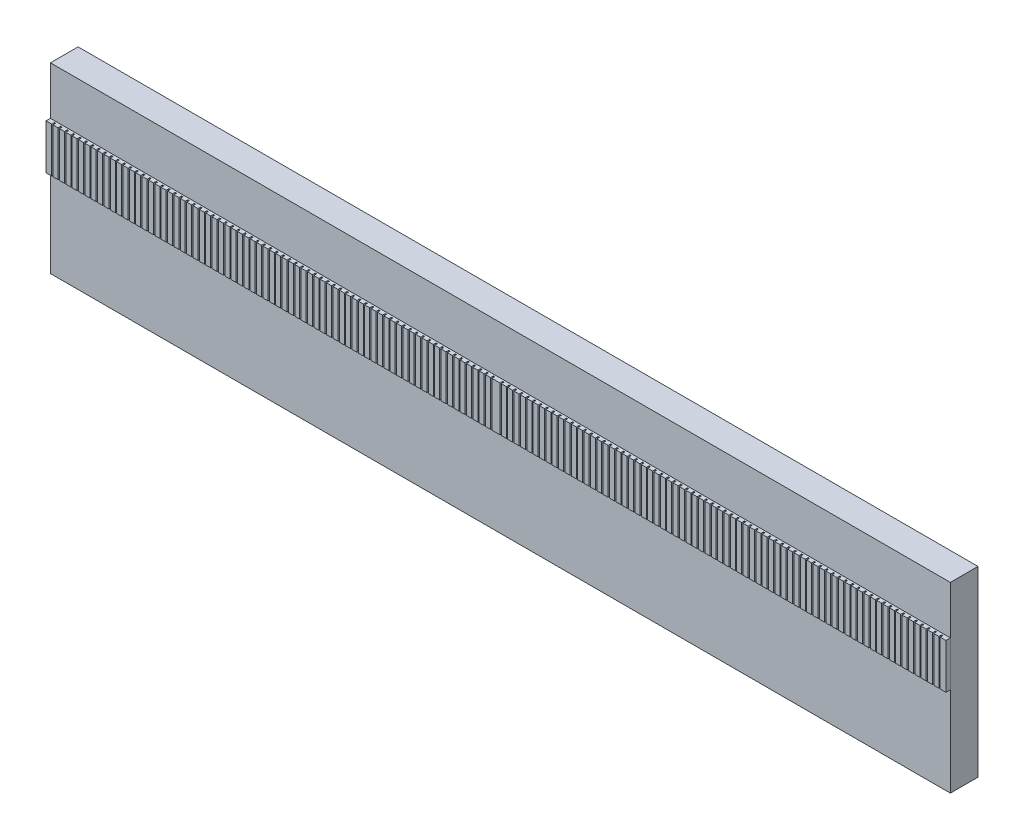
from build123d import *

# Parameters (mm, degrees)
SKETCH1_W           = 32.54
SKETCH1_H           = 6.6
BOSS_EXTRUDE1_DEPTH = 1
SKETCH2_W           = 32.54
SKETCH2_H           = 1.625
BOSS_EXTRUDE2_DEPTH = 0.16
SKETCH3_R           = 0.225
BOSS_EXTRUDE3_DEPTH = 0.25
FILLET1_R           = 0.22
SKETCH5_W           = 0.05
SKETCH5_H           = 1.625
CUT_EXTRUDE1_DEPTH  = 0.1


with BuildPart() as part:
    # Sketch1 → Boss-Extrude1 (new body)
    with BuildSketch(Plane.XY):
        Rectangle(SKETCH1_W, SKETCH1_H)
    extrude(amount=BOSS_EXTRUDE1_DEPTH)

    # Sketch3 → Boss-Extrude3 (add)
    with BuildSketch(Plane(origin=(0, 0, 0), x_dir=(-1, 0, 0), z_dir=(0, 0, -1))):
        with Locations((-0.49, 0.75)):
            Circle(SKETCH3_R)
        with Locations((-1.47, 0.75)):
            Circle(SKETCH3_R)
        with Locations((-2.45, 0.75)):
            Circle(SKETCH3_R)
        with Locations((-3.43, 0.75)):
            Circle(SKETCH3_R)
        with Locations((-4.41, 0.75)):
            Circle(SKETCH3_R)
        with Locations((-5.39, 0.75)):
            Circle(SKETCH3_R)
        with Locations((-6.37, 0.75)):
            Circle(SKETCH3_R)
        with Locations((-7.35, 0.75)):
            Circle(SKETCH3_R)
        with Locations((-8.33, 0.75)):
            Circle(SKETCH3_R)
        with Locations((-9.31, 0.75)):
            Circle(SKETCH3_R)
        with Locations((-10.29, 0.75)):
            Circle(SKETCH3_R)
        with Locations((-11.27, 0.75)):
            Circle(SKETCH3_R)
        with Locations((-12.25, 0.75)):
            Circle(SKETCH3_R)
        with Locations((-13.23, 0.75)):
            Circle(SKETCH3_R)
        with Locations((-14.21, 0.75)):
            Circle(SKETCH3_R)
        with Locations((-15.19, 0.75)):
            Circle(SKETCH3_R)
        with Locations((0, 2.3)):
            Circle(SKETCH3_R)
        with Locations((-0.98, 2.3)):
            Circle(SKETCH3_R)
        with Locations((-1.96, 2.3)):
            Circle(SKETCH3_R)
        with Locations((-2.94, 2.3)):
            Circle(SKETCH3_R)
        with Locations((-3.92, 2.3)):
            Circle(SKETCH3_R)
        with Locations((-4.9, 2.3)):
            Circle(SKETCH3_R)
        with Locations((-5.88, 2.3)):
            Circle(SKETCH3_R)
        with Locations((-6.86, 2.3)):
            Circle(SKETCH3_R)
        with Locations((-7.84, 2.3)):
            Circle(SKETCH3_R)
        with Locations((-8.82, 2.3)):
            Circle(SKETCH3_R)
        with Locations((-9.8, 2.3)):
            Circle(SKETCH3_R)
        with Locations((-10.78, 2.3)):
            Circle(SKETCH3_R)
        with Locations((-11.76, 2.3)):
            Circle(SKETCH3_R)
        with Locations((-12.74, 2.3)):
            Circle(SKETCH3_R)
        with Locations((-13.72, 2.3)):
            Circle(SKETCH3_R)
        with Locations((-14.7, 2.3)):
            Circle(SKETCH3_R)
        with Locations((-15.68, 2.3)):
            Circle(SKETCH3_R)
        with Locations((-0.49, 2.9)):
            Circle(SKETCH3_R)
        with Locations((-1.47, 2.9)):
            Circle(SKETCH3_R)
        with Locations((-2.45, 2.9)):
            Circle(SKETCH3_R)
        with Locations((-3.43, 2.9)):
            Circle(SKETCH3_R)
        with Locations((-4.41, 2.9)):
            Circle(SKETCH3_R)
        with Locations((-5.39, 2.9)):
            Circle(SKETCH3_R)
        with Locations((-6.37, 2.9)):
            Circle(SKETCH3_R)
        with Locations((-7.35, 2.9)):
            Circle(SKETCH3_R)
        with Locations((-8.33, 2.9)):
            Circle(SKETCH3_R)
        with Locations((-9.31, 2.9)):
            Circle(SKETCH3_R)
        with Locations((-10.29, 2.9)):
            Circle(SKETCH3_R)
        with Locations((-11.27, 2.9)):
            Circle(SKETCH3_R)
        with Locations((-12.25, 2.9)):
            Circle(SKETCH3_R)
        with Locations((-13.23, 2.9)):
            Circle(SKETCH3_R)
        with Locations((-14.21, 2.9)):
            Circle(SKETCH3_R)
        with Locations((-15.19, 2.9)):
            Circle(SKETCH3_R)
        with Locations((0.49, 0.75)):
            Circle(SKETCH3_R)
        with Locations((1.47, 0.75)):
            Circle(SKETCH3_R)
        with Locations((2.45, 0.75)):
            Circle(SKETCH3_R)
        with Locations((3.43, 0.75)):
            Circle(SKETCH3_R)
        with Locations((4.41, 0.75)):
            Circle(SKETCH3_R)
        with Locations((5.39, 0.75)):
            Circle(SKETCH3_R)
        with Locations((6.37, 0.75)):
            Circle(SKETCH3_R)
        with Locations((7.35, 0.75)):
            Circle(SKETCH3_R)
        with Locations((8.33, 0.75)):
            Circle(SKETCH3_R)
        with Locations((9.31, 0.75)):
            Circle(SKETCH3_R)
        with Locations((10.29, 0.75)):
            Circle(SKETCH3_R)
        with Locations((11.27, 0.75)):
            Circle(SKETCH3_R)
        with Locations((12.25, 0.75)):
            Circle(SKETCH3_R)
        with Locations((13.23, 0.75)):
            Circle(SKETCH3_R)
        with Locations((14.21, 0.75)):
            Circle(SKETCH3_R)
        with Locations((15.19, 0.75)):
            Circle(SKETCH3_R)
        with Locations((15.68, 2.3)):
            Circle(SKETCH3_R)
        with Locations((14.7, 2.3)):
            Circle(SKETCH3_R)
        with Locations((15.19, 2.9)):
            Circle(SKETCH3_R)
        with Locations((14.21, 2.9)):
            Circle(SKETCH3_R)
        with Locations((13.72, 2.3)):
            Circle(SKETCH3_R)
        with Locations((12.74, 2.3)):
            Circle(SKETCH3_R)
        with Locations((13.23, 2.9)):
            Circle(SKETCH3_R)
        with Locations((12.25, 2.9)):
            Circle(SKETCH3_R)
        with Locations((11.76, 2.3)):
            Circle(SKETCH3_R)
        with Locations((11.27, 2.9)):
            Circle(SKETCH3_R)
        with Locations((10.78, 2.3)):
            Circle(SKETCH3_R)
        with Locations((10.29, 2.9)):
            Circle(SKETCH3_R)
        with Locations((9.31, 2.9)):
            Circle(SKETCH3_R)
        with Locations((9.8, 2.3)):
            Circle(SKETCH3_R)
        with Locations((8.82, 2.3)):
            Circle(SKETCH3_R)
        with Locations((8.33, 2.9)):
            Circle(SKETCH3_R)
        with Locations((7.84, 2.3)):
            Circle(SKETCH3_R)
        with Locations((7.35, 2.9)):
            Circle(SKETCH3_R)
        with Locations((6.37, 2.9)):
            Circle(SKETCH3_R)
        with Locations((6.86, 2.3)):
            Circle(SKETCH3_R)
        with Locations((5.88, 2.3)):
            Circle(SKETCH3_R)
        with Locations((5.39, 2.9)):
            Circle(SKETCH3_R)
        with Locations((4.9, 2.3)):
            Circle(SKETCH3_R)
        with Locations((4.41, 2.9)):
            Circle(SKETCH3_R)
        with Locations((3.92, 2.3)):
            Circle(SKETCH3_R)
        with Locations((3.43, 2.9)):
            Circle(SKETCH3_R)
        with Locations((2.94, 2.3)):
            Circle(SKETCH3_R)
        with Locations((2.45, 2.9)):
            Circle(SKETCH3_R)
        with Locations((1.47, 2.9)):
            Circle(SKETCH3_R)
        with Locations((1.96, 2.3)):
            Circle(SKETCH3_R)
        with Locations((0.98, 2.3)):
            Circle(SKETCH3_R)
        with Locations((0.49, 2.9)):
            Circle(SKETCH3_R)
        with Locations((0.49, -1.4)):
            Circle(SKETCH3_R)
        with Locations((0.98, -0.8)):
            Circle(SKETCH3_R)
        with Locations((1.96, -0.8)):
            Circle(SKETCH3_R)
        with Locations((1.47, -1.4)):
            Circle(SKETCH3_R)
        with Locations((2.45, -1.4)):
            Circle(SKETCH3_R)
        with Locations((2.94, -0.8)):
            Circle(SKETCH3_R)
        with Locations((3.43, -1.4)):
            Circle(SKETCH3_R)
        with Locations((3.92, -0.8)):
            Circle(SKETCH3_R)
        with Locations((4.41, -1.4)):
            Circle(SKETCH3_R)
        with Locations((4.9, -0.8)):
            Circle(SKETCH3_R)
        with Locations((5.39, -1.4)):
            Circle(SKETCH3_R)
        with Locations((5.88, -0.8)):
            Circle(SKETCH3_R)
        with Locations((6.86, -0.8)):
            Circle(SKETCH3_R)
        with Locations((6.37, -1.4)):
            Circle(SKETCH3_R)
        with Locations((7.35, -1.4)):
            Circle(SKETCH3_R)
        with Locations((7.84, -0.8)):
            Circle(SKETCH3_R)
        with Locations((8.33, -1.4)):
            Circle(SKETCH3_R)
        with Locations((8.82, -0.8)):
            Circle(SKETCH3_R)
        with Locations((9.8, -0.8)):
            Circle(SKETCH3_R)
        with Locations((9.31, -1.4)):
            Circle(SKETCH3_R)
        with Locations((10.29, -1.4)):
            Circle(SKETCH3_R)
        with Locations((10.78, -0.8)):
            Circle(SKETCH3_R)
        with Locations((11.27, -1.4)):
            Circle(SKETCH3_R)
        with Locations((11.76, -0.8)):
            Circle(SKETCH3_R)
        with Locations((12.25, -1.4)):
            Circle(SKETCH3_R)
        with Locations((13.23, -1.4)):
            Circle(SKETCH3_R)
        with Locations((12.74, -0.8)):
            Circle(SKETCH3_R)
        with Locations((13.72, -0.8)):
            Circle(SKETCH3_R)
        with Locations((14.21, -1.4)):
            Circle(SKETCH3_R)
        with Locations((15.19, -1.4)):
            Circle(SKETCH3_R)
        with Locations((14.7, -0.8)):
            Circle(SKETCH3_R)
        with Locations((15.68, -0.8)):
            Circle(SKETCH3_R)
        with Locations((-15.19, -1.4)):
            Circle(SKETCH3_R)
        with Locations((-14.21, -1.4)):
            Circle(SKETCH3_R)
        with Locations((-13.23, -1.4)):
            Circle(SKETCH3_R)
        with Locations((-12.25, -1.4)):
            Circle(SKETCH3_R)
        with Locations((-11.27, -1.4)):
            Circle(SKETCH3_R)
        with Locations((-10.29, -1.4)):
            Circle(SKETCH3_R)
        with Locations((-9.31, -1.4)):
            Circle(SKETCH3_R)
        with Locations((-8.33, -1.4)):
            Circle(SKETCH3_R)
        with Locations((-7.35, -1.4)):
            Circle(SKETCH3_R)
        with Locations((-6.37, -1.4)):
            Circle(SKETCH3_R)
        with Locations((-5.39, -1.4)):
            Circle(SKETCH3_R)
        with Locations((-4.41, -1.4)):
            Circle(SKETCH3_R)
        with Locations((-3.43, -1.4)):
            Circle(SKETCH3_R)
        with Locations((-2.45, -1.4)):
            Circle(SKETCH3_R)
        with Locations((-1.47, -1.4)):
            Circle(SKETCH3_R)
        with Locations((-0.49, -1.4)):
            Circle(SKETCH3_R)
        with Locations((-15.68, -0.8)):
            Circle(SKETCH3_R)
        with Locations((-14.7, -0.8)):
            Circle(SKETCH3_R)
        with Locations((-13.72, -0.8)):
            Circle(SKETCH3_R)
        with Locations((-12.74, -0.8)):
            Circle(SKETCH3_R)
        with Locations((-11.76, -0.8)):
            Circle(SKETCH3_R)
        with Locations((-10.78, -0.8)):
            Circle(SKETCH3_R)
        with Locations((-9.8, -0.8)):
            Circle(SKETCH3_R)
        with Locations((-8.82, -0.8)):
            Circle(SKETCH3_R)
        with Locations((-7.84, -0.8)):
            Circle(SKETCH3_R)
        with Locations((-6.86, -0.8)):
            Circle(SKETCH3_R)
        with Locations((-5.88, -0.8)):
            Circle(SKETCH3_R)
        with Locations((-4.9, -0.8)):
            Circle(SKETCH3_R)
        with Locations((-3.92, -0.8)):
            Circle(SKETCH3_R)
        with Locations((-2.94, -0.8)):
            Circle(SKETCH3_R)
        with Locations((-1.96, -0.8)):
            Circle(SKETCH3_R)
        with Locations((-0.98, -0.8)):
            Circle(SKETCH3_R)
        with Locations((0, -0.8)):
            Circle(SKETCH3_R)
    extrude(amount=BOSS_EXTRUDE3_DEPTH)

    # Fillet1
    fillet1_edges = [part.edges().sort_by_distance(p)[0] for p in [
        (9.045, 2.3, -0.25),
        (10.025, 2.3, -0.25),
        (11.005, 2.3, -0.25),
        (11.985, 2.3, -0.25),
        (12.965, 2.3, -0.25),
        (13.945, 2.3, -0.25),
        (14.925, 2.3, -0.25),
        (15.905, 2.3, -0.25),
        (0.715, 2.9, -0.25),
        (-0.265, 0.75, -0.25),
        (1.695, 2.9, -0.25),
        (2.675, 2.9, -0.25),
        (3.655, 2.9, -0.25),
        (4.635, 2.9, -0.25),
        (5.615, 2.9, -0.25),
        (6.595, 2.9, -0.25),
        (7.575, 2.9, -0.25),
        (8.555, 2.9, -0.25),
        (9.535, 2.9, -0.25),
        (10.515, 2.9, -0.25),
        (0.715, 0.75, -0.25),
        (11.495, 2.9, -0.25),
        (12.475, 2.9, -0.25),
        (13.455, 2.9, -0.25),
        (14.435, 2.9, -0.25),
        (15.415, 2.9, -0.25),
        (-1.245, 0.75, -0.25),
        (-2.225, 0.75, -0.25),
        (-3.205, 0.75, -0.25),
        (-4.185, 0.75, -0.25),
        (-5.165, 0.75, -0.25),
        (1.695, 0.75, -0.25),
        (-6.145, 0.75, -0.25),
        (-7.125, 0.75, -0.25),
        (-8.105, 0.75, -0.25),
        (-9.085, 0.75, -0.25),
        (-10.065, 0.75, -0.25),
        (-11.045, 0.75, -0.25),
        (-12.025, 0.75, -0.25),
        (-13.005, 0.75, -0.25),
        (-13.985, 0.75, -0.25),
        (-14.965, 0.75, -0.25),
        (2.675, 0.75, -0.25),
        (-15.455, 2.3, -0.25),
        (-14.475, 2.3, -0.25),
        (-14.965, 2.9, -0.25),
        (-13.985, 2.9, -0.25),
        (-13.495, 2.3, -0.25),
        (-12.515, 2.3, -0.25),
        (-13.005, 2.9, -0.25),
        (-12.025, 2.9, -0.25),
        (-11.535, 2.3, -0.25),
        (-11.045, 2.9, -0.25),
        (3.655, 0.75, -0.25),
        (-10.555, 2.3, -0.25),
        (-10.065, 2.9, -0.25),
        (-9.085, 2.9, -0.25),
        (-9.575, 2.3, -0.25),
        (-8.595, 2.3, -0.25),
        (-8.105, 2.9, -0.25),
        (-7.615, 2.3, -0.25),
        (-7.125, 2.9, -0.25),
        (-6.145, 2.9, -0.25),
        (-6.635, 2.3, -0.25),
        (4.635, 0.75, -0.25),
        (-5.655, 2.3, -0.25),
        (-5.165, 2.9, -0.25),
        (-4.675, 2.3, -0.25),
        (-4.185, 2.9, -0.25),
        (-3.695, 2.3, -0.25),
        (-3.205, 2.9, -0.25),
        (-2.715, 2.3, -0.25),
        (-2.225, 2.9, -0.25),
        (-1.245, 2.9, -0.25),
        (-1.735, 2.3, -0.25),
        (5.615, 0.75, -0.25),
        (-0.755, 2.3, -0.25),
        (-0.265, 2.9, -0.25),
        (-0.265, -1.4, -0.25),
        (-0.755, -0.8, -0.25),
        (-1.735, -0.8, -0.25),
        (-1.245, -1.4, -0.25),
        (-2.225, -1.4, -0.25),
        (-2.715, -0.8, -0.25),
        (-3.205, -1.4, -0.25),
        (-3.695, -0.8, -0.25),
        (6.595, 0.75, -0.25),
        (-4.185, -1.4, -0.25),
        (-4.675, -0.8, -0.25),
        (-5.165, -1.4, -0.25),
        (-5.655, -0.8, -0.25),
        (-6.635, -0.8, -0.25),
        (-6.145, -1.4, -0.25),
        (-7.125, -1.4, -0.25),
        (-7.615, -0.8, -0.25),
        (-8.105, -1.4, -0.25),
        (-8.595, -0.8, -0.25),
        (7.575, 0.75, -0.25),
        (-9.575, -0.8, -0.25),
        (-9.085, -1.4, -0.25),
        (-10.065, -1.4, -0.25),
        (-10.555, -0.8, -0.25),
        (-11.045, -1.4, -0.25),
        (-11.535, -0.8, -0.25),
        (-12.025, -1.4, -0.25),
        (-13.005, -1.4, -0.25),
        (-12.515, -0.8, -0.25),
        (-13.495, -0.8, -0.25),
        (8.555, 0.75, -0.25),
        (-13.985, -1.4, -0.25),
        (-14.965, -1.4, -0.25),
        (-14.475, -0.8, -0.25),
        (-15.455, -0.8, -0.25),
        (15.415, -1.4, -0.25),
        (14.435, -1.4, -0.25),
        (13.455, -1.4, -0.25),
        (12.475, -1.4, -0.25),
        (11.495, -1.4, -0.25),
        (10.515, -1.4, -0.25),
        (9.535, 0.75, -0.25),
        (9.535, -1.4, -0.25),
        (8.555, -1.4, -0.25),
        (7.575, -1.4, -0.25),
        (6.595, -1.4, -0.25),
        (5.615, -1.4, -0.25),
        (4.635, -1.4, -0.25),
        (3.655, -1.4, -0.25),
        (2.675, -1.4, -0.25),
        (1.695, -1.4, -0.25),
        (0.715, -1.4, -0.25),
        (10.515, 0.75, -0.25),
        (15.905, -0.8, -0.25),
        (14.925, -0.8, -0.25),
        (13.945, -0.8, -0.25),
        (12.965, -0.8, -0.25),
        (11.985, -0.8, -0.25),
        (11.005, -0.8, -0.25),
        (10.025, -0.8, -0.25),
        (9.045, -0.8, -0.25),
        (8.065, -0.8, -0.25),
        (7.085, -0.8, -0.25),
        (11.495, 0.75, -0.25),
        (6.105, -0.8, -0.25),
        (5.125, -0.8, -0.25),
        (4.145, -0.8, -0.25),
        (3.165, -0.8, -0.25),
        (2.185, -0.8, -0.25),
        (0.225, -0.8, -0.25),
        (1.205, -0.8, -0.25),
        (12.475, 0.75, -0.25),
        (13.455, 0.75, -0.25),
        (14.435, 0.75, -0.25),
        (15.415, 0.75, -0.25),
        (0.225, 2.3, -0.25),
        (1.205, 2.3, -0.25),
        (2.185, 2.3, -0.25),
        (3.165, 2.3, -0.25),
        (4.145, 2.3, -0.25),
        (5.125, 2.3, -0.25),
        (6.105, 2.3, -0.25),
        (7.085, 2.3, -0.25),
        (8.065, 2.3, -0.25),
    ]]
    fillet(fillet1_edges, radius=FILLET1_R)


with BuildPart() as body_2:
    # Sketch2 → Boss-Extrude2 (new body)
    with BuildSketch(Plane.XY.offset(1)):
        with Locations((0, 0.75)):
            Rectangle(SKETCH2_W, SKETCH2_H)
    extrude(amount=BOSS_EXTRUDE2_DEPTH)

    # Sketch5 → Cut-Extrude1 (cut)
    with BuildSketch(Plane.XY.offset(1.16)):
        with Locations((-16.04, 0.75)):
            Rectangle(SKETCH5_W, SKETCH5_H)
        with Locations((-15.81, 0.75)):
            Rectangle(SKETCH5_W, SKETCH5_H)
        with Locations((-15.58, 0.75)):
            Rectangle(SKETCH5_W, SKETCH5_H)
        with Locations((-15.35, 0.75)):
            Rectangle(SKETCH5_W, SKETCH5_H)
        with Locations((-15.12, 0.75)):
            Rectangle(SKETCH5_W, SKETCH5_H)
        with Locations((-14.89, 0.75)):
            Rectangle(SKETCH5_W, SKETCH5_H)
        with Locations((-14.66, 0.75)):
            Rectangle(SKETCH5_W, SKETCH5_H)
        with Locations((-14.43, 0.75)):
            Rectangle(SKETCH5_W, SKETCH5_H)
        with Locations((-14.2, 0.75)):
            Rectangle(SKETCH5_W, SKETCH5_H)
        with Locations((-13.97, 0.75)):
            Rectangle(SKETCH5_W, SKETCH5_H)
        with Locations((-13.74, 0.75)):
            Rectangle(SKETCH5_W, SKETCH5_H)
        with Locations((-13.51, 0.75)):
            Rectangle(SKETCH5_W, SKETCH5_H)
        with Locations((-13.28, 0.75)):
            Rectangle(SKETCH5_W, SKETCH5_H)
        with Locations((-13.05, 0.75)):
            Rectangle(SKETCH5_W, SKETCH5_H)
        with Locations((-12.82, 0.75)):
            Rectangle(SKETCH5_W, SKETCH5_H)
        with Locations((-12.59, 0.75)):
            Rectangle(SKETCH5_W, SKETCH5_H)
        with Locations((-12.36, 0.75)):
            Rectangle(SKETCH5_W, SKETCH5_H)
        with Locations((-12.13, 0.75)):
            Rectangle(SKETCH5_W, SKETCH5_H)
        with Locations((-11.9, 0.75)):
            Rectangle(SKETCH5_W, SKETCH5_H)
        with Locations((-11.67, 0.75)):
            Rectangle(SKETCH5_W, SKETCH5_H)
        with Locations((-11.44, 0.75)):
            Rectangle(SKETCH5_W, SKETCH5_H)
        with Locations((-11.21, 0.75)):
            Rectangle(SKETCH5_W, SKETCH5_H)
        with Locations((-10.98, 0.75)):
            Rectangle(SKETCH5_W, SKETCH5_H)
        with Locations((-10.75, 0.75)):
            Rectangle(SKETCH5_W, SKETCH5_H)
        with Locations((-10.52, 0.75)):
            Rectangle(SKETCH5_W, SKETCH5_H)
        with Locations((-10.29, 0.75)):
            Rectangle(SKETCH5_W, SKETCH5_H)
        with Locations((-10.06, 0.75)):
            Rectangle(SKETCH5_W, SKETCH5_H)
        with Locations((-9.83, 0.75)):
            Rectangle(SKETCH5_W, SKETCH5_H)
        with Locations((-9.6, 0.75)):
            Rectangle(SKETCH5_W, SKETCH5_H)
        with Locations((-9.37, 0.75)):
            Rectangle(SKETCH5_W, SKETCH5_H)
        with Locations((-9.14, 0.75)):
            Rectangle(SKETCH5_W, SKETCH5_H)
        with Locations((-8.91, 0.75)):
            Rectangle(SKETCH5_W, SKETCH5_H)
        with Locations((-8.68, 0.75)):
            Rectangle(SKETCH5_W, SKETCH5_H)
        with Locations((-8.45, 0.75)):
            Rectangle(SKETCH5_W, SKETCH5_H)
        with Locations((-8.22, 0.75)):
            Rectangle(SKETCH5_W, SKETCH5_H)
        with Locations((-7.99, 0.75)):
            Rectangle(SKETCH5_W, SKETCH5_H)
        with Locations((-7.76, 0.75)):
            Rectangle(SKETCH5_W, SKETCH5_H)
        with Locations((-7.53, 0.75)):
            Rectangle(SKETCH5_W, SKETCH5_H)
        with Locations((-7.3, 0.75)):
            Rectangle(SKETCH5_W, SKETCH5_H)
        with Locations((-7.07, 0.75)):
            Rectangle(SKETCH5_W, SKETCH5_H)
        with Locations((-6.84, 0.75)):
            Rectangle(SKETCH5_W, SKETCH5_H)
        with Locations((-6.61, 0.75)):
            Rectangle(SKETCH5_W, SKETCH5_H)
        with Locations((-6.38, 0.75)):
            Rectangle(SKETCH5_W, SKETCH5_H)
        with Locations((-6.15, 0.75)):
            Rectangle(SKETCH5_W, SKETCH5_H)
        with Locations((-5.92, 0.75)):
            Rectangle(SKETCH5_W, SKETCH5_H)
        with Locations((-5.69, 0.75)):
            Rectangle(SKETCH5_W, SKETCH5_H)
        with Locations((-5.46, 0.75)):
            Rectangle(SKETCH5_W, SKETCH5_H)
        with Locations((-5.23, 0.75)):
            Rectangle(SKETCH5_W, SKETCH5_H)
        with Locations((-5, 0.75)):
            Rectangle(SKETCH5_W, SKETCH5_H)
        with Locations((-4.77, 0.75)):
            Rectangle(SKETCH5_W, SKETCH5_H)
        with Locations((-4.54, 0.75)):
            Rectangle(SKETCH5_W, SKETCH5_H)
        with Locations((-4.31, 0.75)):
            Rectangle(SKETCH5_W, SKETCH5_H)
        with Locations((-4.08, 0.75)):
            Rectangle(SKETCH5_W, SKETCH5_H)
        with Locations((-3.85, 0.75)):
            Rectangle(SKETCH5_W, SKETCH5_H)
        with Locations((-3.62, 0.75)):
            Rectangle(SKETCH5_W, SKETCH5_H)
        with Locations((-3.39, 0.75)):
            Rectangle(SKETCH5_W, SKETCH5_H)
        with Locations((-3.16, 0.75)):
            Rectangle(SKETCH5_W, SKETCH5_H)
        with Locations((-2.93, 0.75)):
            Rectangle(SKETCH5_W, SKETCH5_H)
        with Locations((-2.7, 0.75)):
            Rectangle(SKETCH5_W, SKETCH5_H)
        with Locations((-2.47, 0.75)):
            Rectangle(SKETCH5_W, SKETCH5_H)
        with Locations((-2.24, 0.75)):
            Rectangle(SKETCH5_W, SKETCH5_H)
        with Locations((-2.01, 0.75)):
            Rectangle(SKETCH5_W, SKETCH5_H)
        with Locations((-1.78, 0.75)):
            Rectangle(SKETCH5_W, SKETCH5_H)
        with Locations((-1.55, 0.75)):
            Rectangle(SKETCH5_W, SKETCH5_H)
        with Locations((-1.32, 0.75)):
            Rectangle(SKETCH5_W, SKETCH5_H)
        with Locations((-1.09, 0.75)):
            Rectangle(SKETCH5_W, SKETCH5_H)
        with Locations((-0.86, 0.75)):
            Rectangle(SKETCH5_W, SKETCH5_H)
        with Locations((-0.63, 0.75)):
            Rectangle(SKETCH5_W, SKETCH5_H)
        with Locations((-0.4, 0.75)):
            Rectangle(SKETCH5_W, SKETCH5_H)
        with Locations((-0.17, 0.75)):
            Rectangle(SKETCH5_W, SKETCH5_H)
        with Locations((0.17, 0.75)):
            Rectangle(SKETCH5_W, SKETCH5_H)
        with Locations((0.4, 0.75)):
            Rectangle(SKETCH5_W, SKETCH5_H)
        with Locations((0.63, 0.75)):
            Rectangle(SKETCH5_W, SKETCH5_H)
        with Locations((0.86, 0.75)):
            Rectangle(SKETCH5_W, SKETCH5_H)
        with Locations((1.09, 0.75)):
            Rectangle(SKETCH5_W, SKETCH5_H)
        with Locations((1.32, 0.75)):
            Rectangle(SKETCH5_W, SKETCH5_H)
        with Locations((1.55, 0.75)):
            Rectangle(SKETCH5_W, SKETCH5_H)
        with Locations((1.78, 0.75)):
            Rectangle(SKETCH5_W, SKETCH5_H)
        with Locations((2.01, 0.75)):
            Rectangle(SKETCH5_W, SKETCH5_H)
        with Locations((2.24, 0.75)):
            Rectangle(SKETCH5_W, SKETCH5_H)
        with Locations((2.47, 0.75)):
            Rectangle(SKETCH5_W, SKETCH5_H)
        with Locations((2.7, 0.75)):
            Rectangle(SKETCH5_W, SKETCH5_H)
        with Locations((2.93, 0.75)):
            Rectangle(SKETCH5_W, SKETCH5_H)
        with Locations((3.16, 0.75)):
            Rectangle(SKETCH5_W, SKETCH5_H)
        with Locations((3.39, 0.75)):
            Rectangle(SKETCH5_W, SKETCH5_H)
        with Locations((3.62, 0.75)):
            Rectangle(SKETCH5_W, SKETCH5_H)
        with Locations((3.85, 0.75)):
            Rectangle(SKETCH5_W, SKETCH5_H)
        with Locations((4.08, 0.75)):
            Rectangle(SKETCH5_W, SKETCH5_H)
        with Locations((4.31, 0.75)):
            Rectangle(SKETCH5_W, SKETCH5_H)
        with Locations((4.54, 0.75)):
            Rectangle(SKETCH5_W, SKETCH5_H)
        with Locations((4.77, 0.75)):
            Rectangle(SKETCH5_W, SKETCH5_H)
        with Locations((5, 0.75)):
            Rectangle(SKETCH5_W, SKETCH5_H)
        with Locations((5.23, 0.75)):
            Rectangle(SKETCH5_W, SKETCH5_H)
        with Locations((5.46, 0.75)):
            Rectangle(SKETCH5_W, SKETCH5_H)
        with Locations((5.69, 0.75)):
            Rectangle(SKETCH5_W, SKETCH5_H)
        with Locations((5.92, 0.75)):
            Rectangle(SKETCH5_W, SKETCH5_H)
        with Locations((6.15, 0.75)):
            Rectangle(SKETCH5_W, SKETCH5_H)
        with Locations((6.38, 0.75)):
            Rectangle(SKETCH5_W, SKETCH5_H)
        with Locations((6.61, 0.75)):
            Rectangle(SKETCH5_W, SKETCH5_H)
        with Locations((6.84, 0.75)):
            Rectangle(SKETCH5_W, SKETCH5_H)
        with Locations((7.07, 0.75)):
            Rectangle(SKETCH5_W, SKETCH5_H)
        with Locations((7.3, 0.75)):
            Rectangle(SKETCH5_W, SKETCH5_H)
        with Locations((7.53, 0.75)):
            Rectangle(SKETCH5_W, SKETCH5_H)
        with Locations((7.76, 0.75)):
            Rectangle(SKETCH5_W, SKETCH5_H)
        with Locations((7.99, 0.75)):
            Rectangle(SKETCH5_W, SKETCH5_H)
        with Locations((8.22, 0.75)):
            Rectangle(SKETCH5_W, SKETCH5_H)
        with Locations((8.45, 0.75)):
            Rectangle(SKETCH5_W, SKETCH5_H)
        with Locations((8.68, 0.75)):
            Rectangle(SKETCH5_W, SKETCH5_H)
        with Locations((8.91, 0.75)):
            Rectangle(SKETCH5_W, SKETCH5_H)
        with Locations((9.14, 0.75)):
            Rectangle(SKETCH5_W, SKETCH5_H)
        with Locations((9.37, 0.75)):
            Rectangle(SKETCH5_W, SKETCH5_H)
        with Locations((9.6, 0.75)):
            Rectangle(SKETCH5_W, SKETCH5_H)
        with Locations((9.83, 0.75)):
            Rectangle(SKETCH5_W, SKETCH5_H)
        with Locations((10.06, 0.75)):
            Rectangle(SKETCH5_W, SKETCH5_H)
        with Locations((10.29, 0.75)):
            Rectangle(SKETCH5_W, SKETCH5_H)
        with Locations((10.52, 0.75)):
            Rectangle(SKETCH5_W, SKETCH5_H)
        with Locations((10.75, 0.75)):
            Rectangle(SKETCH5_W, SKETCH5_H)
        with Locations((10.98, 0.75)):
            Rectangle(SKETCH5_W, SKETCH5_H)
        with Locations((11.21, 0.75)):
            Rectangle(SKETCH5_W, SKETCH5_H)
        with Locations((11.44, 0.75)):
            Rectangle(SKETCH5_W, SKETCH5_H)
        with Locations((11.67, 0.75)):
            Rectangle(SKETCH5_W, SKETCH5_H)
        with Locations((11.9, 0.75)):
            Rectangle(SKETCH5_W, SKETCH5_H)
        with Locations((12.13, 0.75)):
            Rectangle(SKETCH5_W, SKETCH5_H)
        with Locations((12.36, 0.75)):
            Rectangle(SKETCH5_W, SKETCH5_H)
        with Locations((12.59, 0.75)):
            Rectangle(SKETCH5_W, SKETCH5_H)
        with Locations((12.82, 0.75)):
            Rectangle(SKETCH5_W, SKETCH5_H)
        with Locations((13.05, 0.75)):
            Rectangle(SKETCH5_W, SKETCH5_H)
        with Locations((13.28, 0.75)):
            Rectangle(SKETCH5_W, SKETCH5_H)
        with Locations((13.51, 0.75)):
            Rectangle(SKETCH5_W, SKETCH5_H)
        with Locations((13.74, 0.75)):
            Rectangle(SKETCH5_W, SKETCH5_H)
        with Locations((13.97, 0.75)):
            Rectangle(SKETCH5_W, SKETCH5_H)
        with Locations((14.2, 0.75)):
            Rectangle(SKETCH5_W, SKETCH5_H)
        with Locations((14.43, 0.75)):
            Rectangle(SKETCH5_W, SKETCH5_H)
        with Locations((14.66, 0.75)):
            Rectangle(SKETCH5_W, SKETCH5_H)
        with Locations((14.89, 0.75)):
            Rectangle(SKETCH5_W, SKETCH5_H)
        with Locations((15.12, 0.75)):
            Rectangle(SKETCH5_W, SKETCH5_H)
        with Locations((15.35, 0.75)):
            Rectangle(SKETCH5_W, SKETCH5_H)
        with Locations((15.58, 0.75)):
            Rectangle(SKETCH5_W, SKETCH5_H)
        with Locations((15.81, 0.75)):
            Rectangle(SKETCH5_W, SKETCH5_H)
        with Locations((16.04, 0.75)):
            Rectangle(SKETCH5_W, SKETCH5_H)
    extrude(amount=-CUT_EXTRUDE1_DEPTH, mode=Mode.SUBTRACT)


solid = Compound([part.part, body_2.part])
